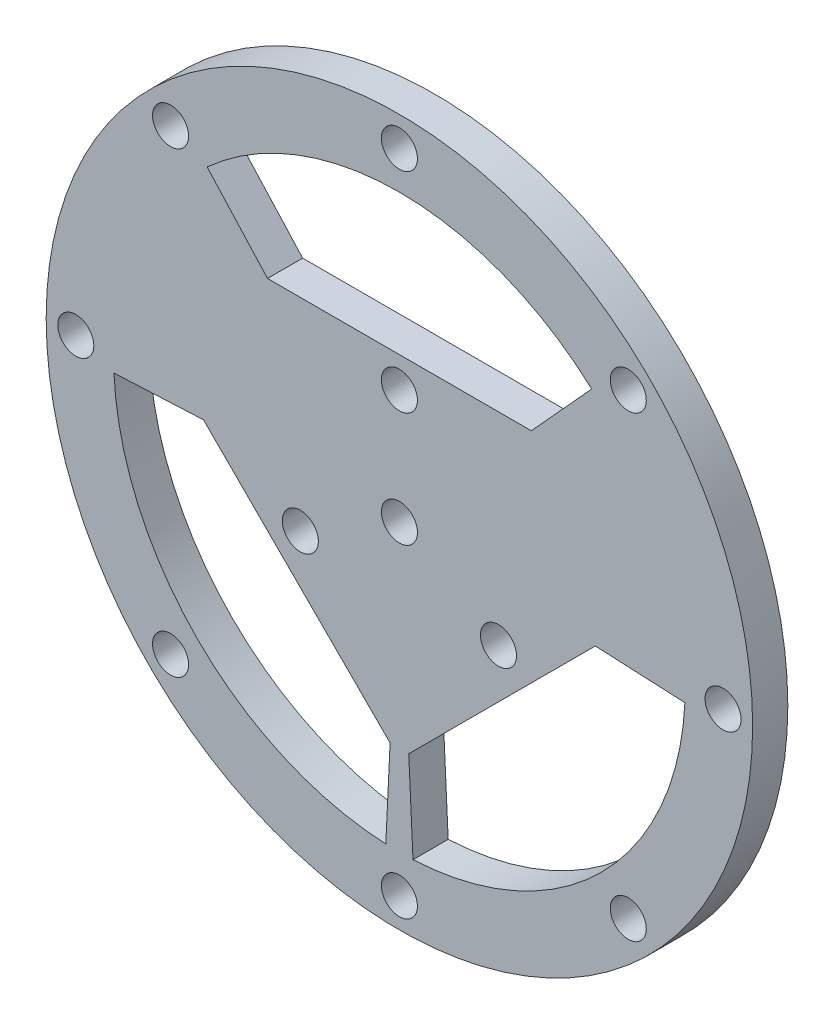
from build123d import *

# Parameters (mm, degrees)
SKETCH_1_R      = 80.33713036
SKETCH_1_R_2    = 4.1
EXTRUDE_1_DEPTH = 8


with BuildPart() as part:
    # 草图1 → 凸台-拉伸1 (new body)
    with BuildSketch(Plane.XY):
        Circle(SKETCH_1_R)
        with Locations((0, 73.60266962)):
            Circle(SKETCH_1_R_2, mode=Mode.SUBTRACT)
        with Locations((-52.044946802, 52.044946802)):
            Circle(SKETCH_1_R_2, mode=Mode.SUBTRACT)
        with Locations((-73.60266962, 0)):
            Circle(SKETCH_1_R_2, mode=Mode.SUBTRACT)
        with Locations((-52.044946802, -52.044946802)):
            Circle(SKETCH_1_R_2, mode=Mode.SUBTRACT)
        with Locations((0, -73.60266962)):
            Circle(SKETCH_1_R_2, mode=Mode.SUBTRACT)
        with Locations((52.044946802, -52.044946802)):
            Circle(SKETCH_1_R_2, mode=Mode.SUBTRACT)
        with Locations((73.60266962, 0)):
            Circle(SKETCH_1_R_2, mode=Mode.SUBTRACT)
        with Locations((52.044946802, 52.044946802)):
            Circle(SKETCH_1_R_2, mode=Mode.SUBTRACT)
        with Locations((0, 26.022473401)):
            Circle(SKETCH_1_R_2, mode=Mode.SUBTRACT)
        with Locations((22.536123034, -13.0112367)):
            Circle(SKETCH_1_R_2, mode=Mode.SUBTRACT)
        with Locations((-22.536123034, -13.0112367)):
            Circle(SKETCH_1_R_2, mode=Mode.SUBTRACT)
        Circle(SKETCH_1_R_2, mode=Mode.SUBTRACT)
        with BuildLine():
            Line((43.72373161, 48.096104771), (30, 33))
            Line((30, 33), (-30, 33))
            Line((-30, 33), (-43.72373161, 48.096104771))
            ThreePointArc((-43.72373161, 48.096104771), (0, 65), (43.72373161, 48.096104771))
        make_face(mode=Mode.SUBTRACT)
        with BuildLine():
            Line((-64.926428952, -3.091734712), (-44.547727215, -2.121320344))
            Line((-44.547727215, -2.121320344), (-2.121320344, -44.547727215))
            Line((-2.121320344, -44.547727215), (-3.091734712, -64.926428952))
            ThreePointArc((-3.091734712, -64.926428952), (-45.961940777, -45.961940777), (-64.926428952, -3.091734712))
        make_face(mode=Mode.SUBTRACT)
        with BuildLine():
            Line((3.091734712, -64.926428952), (2.121320344, -44.547727215))
            Line((2.121320344, -44.547727215), (44.547727215, -2.121320344))
            Line((44.547727215, -2.121320344), (64.926428952, -3.091734712))
            ThreePointArc((64.926428952, -3.091734712), (45.961940777, -45.961940777), (3.091734712, -64.926428952))
        make_face(mode=Mode.SUBTRACT)
    extrude(amount=EXTRUDE_1_DEPTH)


solid = part.part
